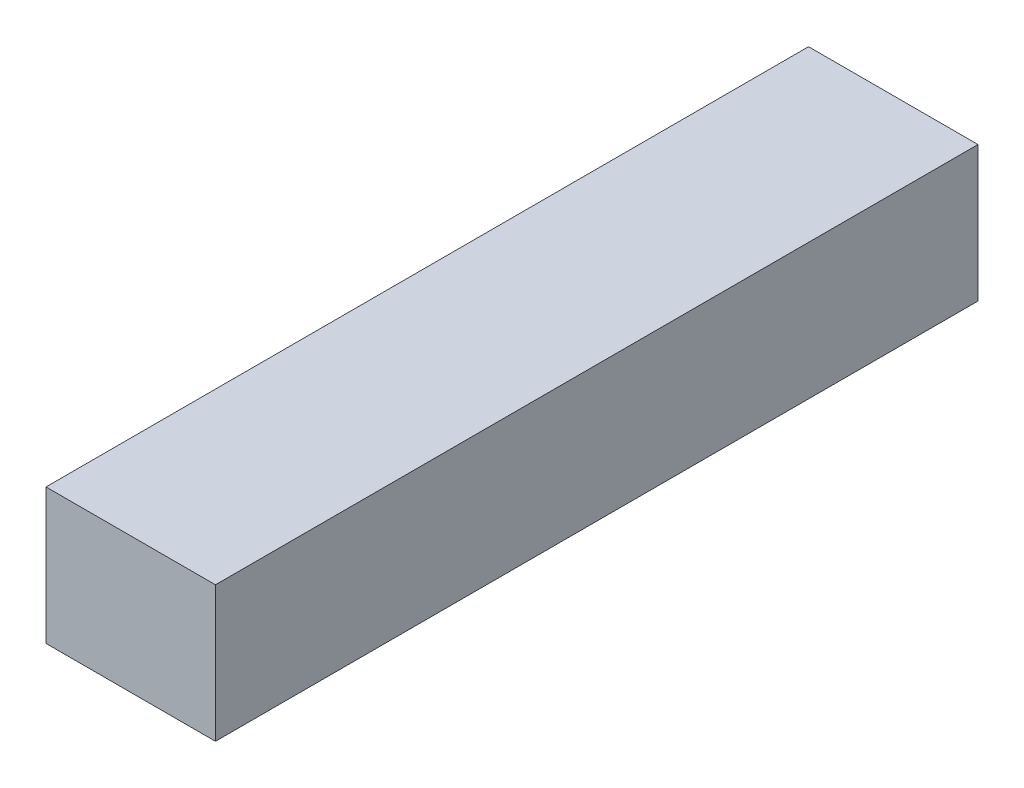
from build123d import *

# Parameters (mm, degrees)
SKETCH1_W           = 10
SKETCH1_H           = 8
BOSS_EXTRUDE1_DEPTH = 45


with BuildPart() as part:
    # Sketch1 → Boss-Extrude1 (new body)
    with BuildSketch(Plane.XY):
        with Locations((5, -4)):
            Rectangle(SKETCH1_W, SKETCH1_H)
    extrude(amount=-BOSS_EXTRUDE1_DEPTH)


solid = part.part
